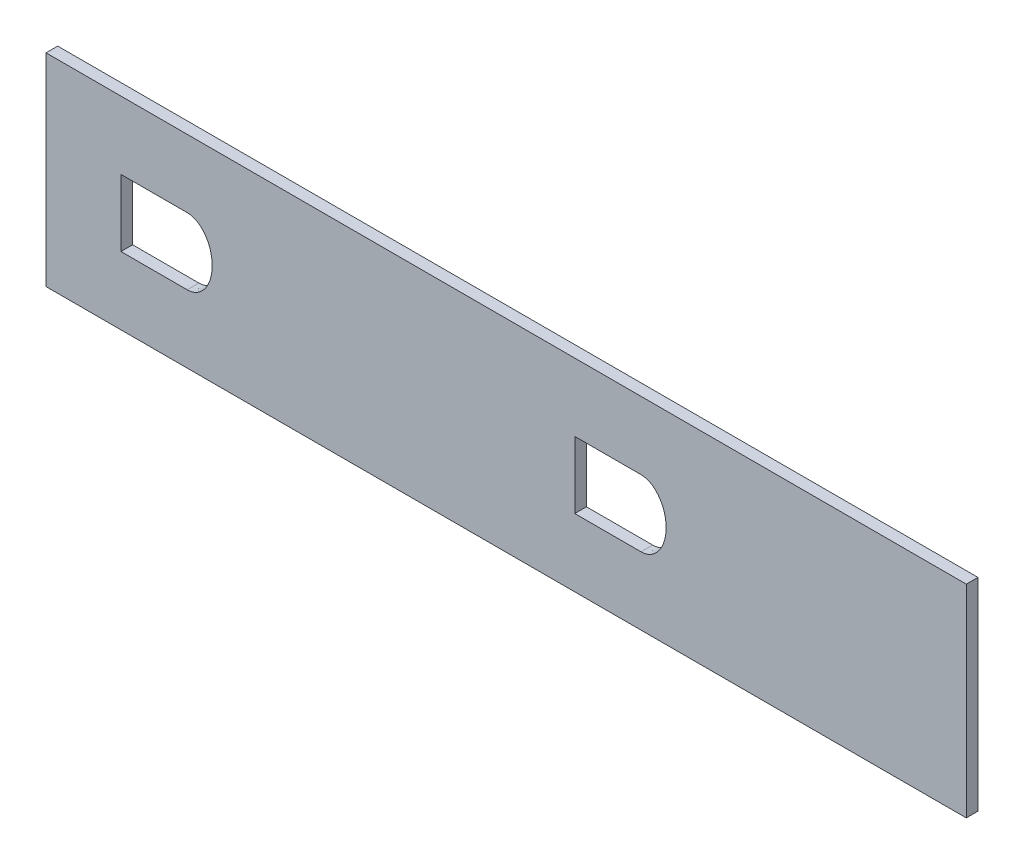
from build123d import *

# Parameters (mm, degrees)
SKETCH1_W           = 250
SKETCH1_H           = 55
BOSS_EXTRUDE1_DEPTH = 3.175


with BuildPart() as part:
    # Sketch1 → Boss-Extrude1 (new body)
    with BuildSketch(Plane.XY):
        with Locations((241.58829827, 101.583069701)):
            Rectangle(SKETCH1_W, SKETCH1_H)
        with BuildLine():
            Line((154.944441507, 110.659419863), (136.944461656, 110.659419863))
            Line((136.944461656, 110.659419863), (136.944461656, 92.511783047))
            Line((136.944461656, 92.511783047), (154.944461656, 92.511783047))
            add(Edge.make_bspline(
                [(154.944461656, 92.511783047), (155.465580761, 92.511783047), (155.973562735, 92.589394234), (156.720262524, 92.818020166), (156.967329601, 92.914210046), (157.440562636, 93.137067615), (157.668709975, 93.264289684), (158.109361081, 93.547905878), (158.322848527, 93.705295338), (158.725811926, 94.039877695), (158.91636517, 94.217573511), (159.277979375, 94.591523132), (159.449028618, 94.787788094), (159.773040585, 95.19753762), (159.9266746, 95.412129059), (160.355672211, 96.071269052), (160.599679107, 96.530127084), (161.016221353, 97.480916259), (161.18895181, 97.974269403), (161.602577216, 99.493122012), (161.733592644, 100.524931205), (161.735557125, 102.623122345), (161.605853876, 103.65367904), (161.200790672, 105.159416327), (161.028182443, 105.658994331), (160.612184007, 106.616383577), (160.369184421, 107.075786107), (159.803943699, 107.950913477), (159.477972126, 108.370019434), (158.755362198, 109.122883671), (158.357777017, 109.46022215), (157.472283398, 110.03638962), (157.002434247, 110.263188923), (156.251245807, 110.498433872), (155.99218216, 110.558924387), (155.475823647, 110.638710894), (155.216383747, 110.658836286), (154.951945719, 110.659415753), (154.948193937, 110.659419863), (154.944441507, 110.659419863)],
                knots=[0.000439911, 0.000439911, 0.000439911, 0.000439911, 0.03125, 0.03125, 0.046875, 0.046875, 0.0625, 0.0625, 0.078125, 0.078125, 0.09375, 0.09375, 0.109375, 0.109375, 0.125, 0.125, 0.15625, 0.15625, 0.1875, 0.1875, 0.25, 0.25, 0.3125, 0.3125, 0.34375, 0.34375, 0.375, 0.375, 0.40625, 0.40625, 0.4375, 0.4375, 0.46875, 0.46875, 0.484375, 0.484375, 0.5, 0.5, 0.500224833, 0.500224833, 0.500224833, 0.500224833], degree=3))
        make_face(mode=Mode.SUBTRACT)
        with BuildLine():
            Line((278.222355303, 110.659419984), (260.222355303, 110.659419984))
            Line((260.222355303, 110.659419984), (260.222355303, 92.511784216))
            Line((260.222355303, 92.511784216), (278.222671977, 92.511784216))
            add(Edge.make_bspline(
                [(278.222671977, 92.511784216), (278.229937143, 92.511784216), (278.237201457, 92.511799646), (278.773421896, 92.514079257), (279.288142612, 92.596096823), (280.040047699, 92.832172325), (280.286553449, 92.929971913), (280.75860243, 93.155562646), (280.986126812, 93.283918002), (281.425506637, 93.569311707), (281.638411532, 93.727382623), (282.040609192, 94.063197756), (282.23082338, 94.241332646), (282.591831943, 94.615849486), (282.762614605, 94.81224244), (283.086151949, 95.22196763), (283.239528043, 95.436304512), (283.668884519, 96.096080467), (283.913097501, 96.555038053), (284.329853528, 97.5055387), (284.50233093, 97.997517385), (284.916425114, 99.517971017), (285.04637802, 100.549745307), (285.044814782, 102.121799944), (285.010624567, 102.644051201), (284.87506084, 103.671879074), (284.773756367, 104.179515711), (284.56808419, 104.930912138), (284.490533245, 105.179693519), (284.316216828, 105.673658252), (284.219380859, 105.918716085), (283.90344552, 106.635729238), (283.657868712, 107.093856456), (283.088219022, 107.965462), (282.760173435, 108.382711445), (282.033463395, 109.132471136), (281.634553418, 109.467765519), (280.748361649, 110.039964654), (280.276240557, 110.266288645), (279.525605581, 110.499795693), (279.266245361, 110.559993759), (278.749131979, 110.639237799), (278.489592579, 110.659075845), (278.226841712, 110.659418521), (278.224598593, 110.659419984), (278.222355303, 110.659419984)],
                knots=[0.999570895, 0.999570895, 0.999570895, 0.999570895, 1, 1, 1.03125, 1.03125, 1.046875, 1.046875, 1.0625, 1.0625, 1.078125, 1.078125, 1.09375, 1.09375, 1.109375, 1.109375, 1.125, 1.125, 1.15625, 1.15625, 1.1875, 1.1875, 1.25, 1.25, 1.28125, 1.28125, 1.3125, 1.3125, 1.328125, 1.328125, 1.34375, 1.34375, 1.375, 1.375, 1.40625, 1.40625, 1.4375, 1.4375, 1.46875, 1.46875, 1.484375, 1.484375, 1.5, 1.5, 1.50013453, 1.50013453, 1.50013453, 1.50013453], degree=3))
        make_face(mode=Mode.SUBTRACT)
    extrude(amount=BOSS_EXTRUDE1_DEPTH)


solid = part.part
